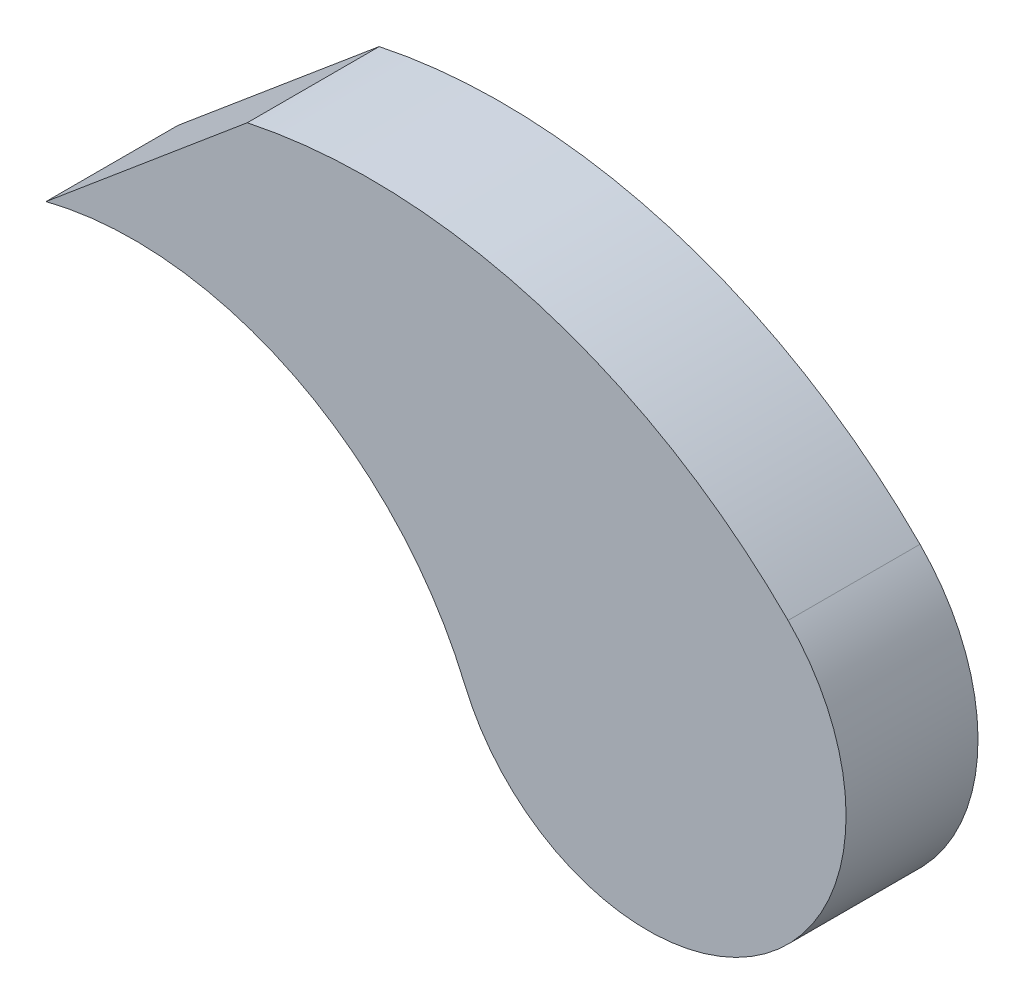
from build123d import *

# Parameters (mm, degrees)
BOSS_EXTRUDE1_DEPTH = 3.175


with BuildPart() as part:
    # Sketch1 → Boss-Extrude1 (new body)
    with BuildSketch(Plane.XY):
        with BuildLine():
            Line((-9.6347134, 7.239), (-14.478, 3.175))
            ThreePointArc((-14.478, 3.175), (-8.508269293, 2.530039511), (-4.401941139, -1.850796922))
            ThreePointArc((-4.401941139, -1.850796922), (2.661951762, -3.964410153), (3.379202957, 3.373947601))
            ThreePointArc((3.379202957, 3.373947601), (-2.636893343, 6.959241932), (-9.6347134, 7.239))
        make_face()
    extrude(amount=BOSS_EXTRUDE1_DEPTH)


solid = part.part
